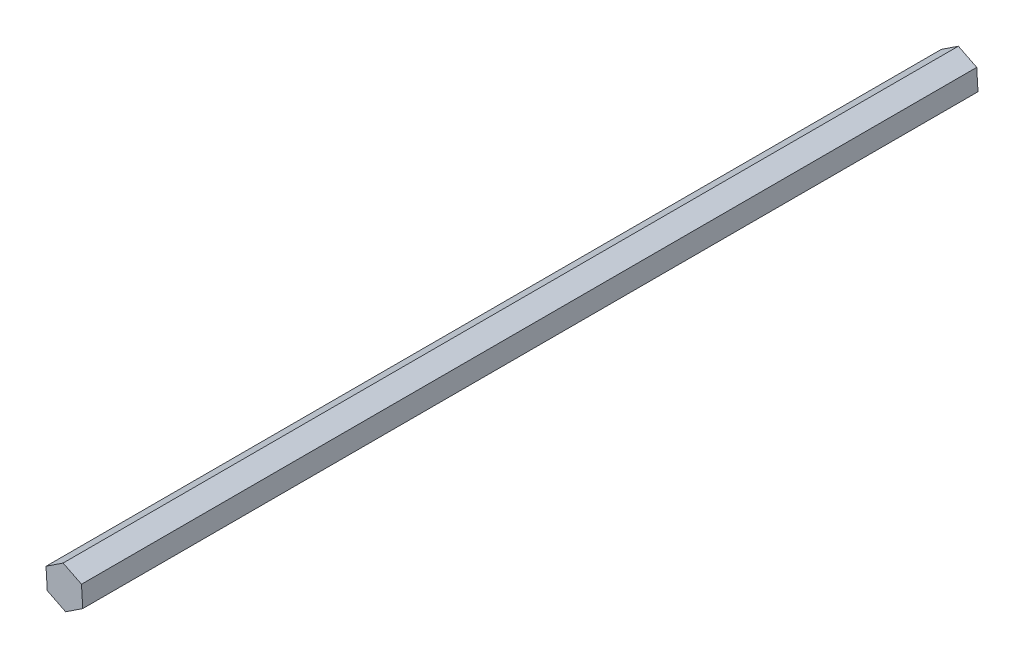
from build123d import *

# Parameters (mm, degrees)
BOSS_EXTRUDE1_DEPTH = 320.55


with BuildPart() as part:
    # Sketch1 → Boss-Extrude1 (new body)
    with BuildSketch(Plane.XY):
        Polygon((-0.45377191, 7.335979216), (-6.580030318, 3.275011606), (-6.126258407, -4.06096761), (0.45377191, -7.335979216), (6.580030318, -3.275011606), (6.126258407, 4.06096761), align=None)
    extrude(amount=BOSS_EXTRUDE1_DEPTH)


solid = part.part
